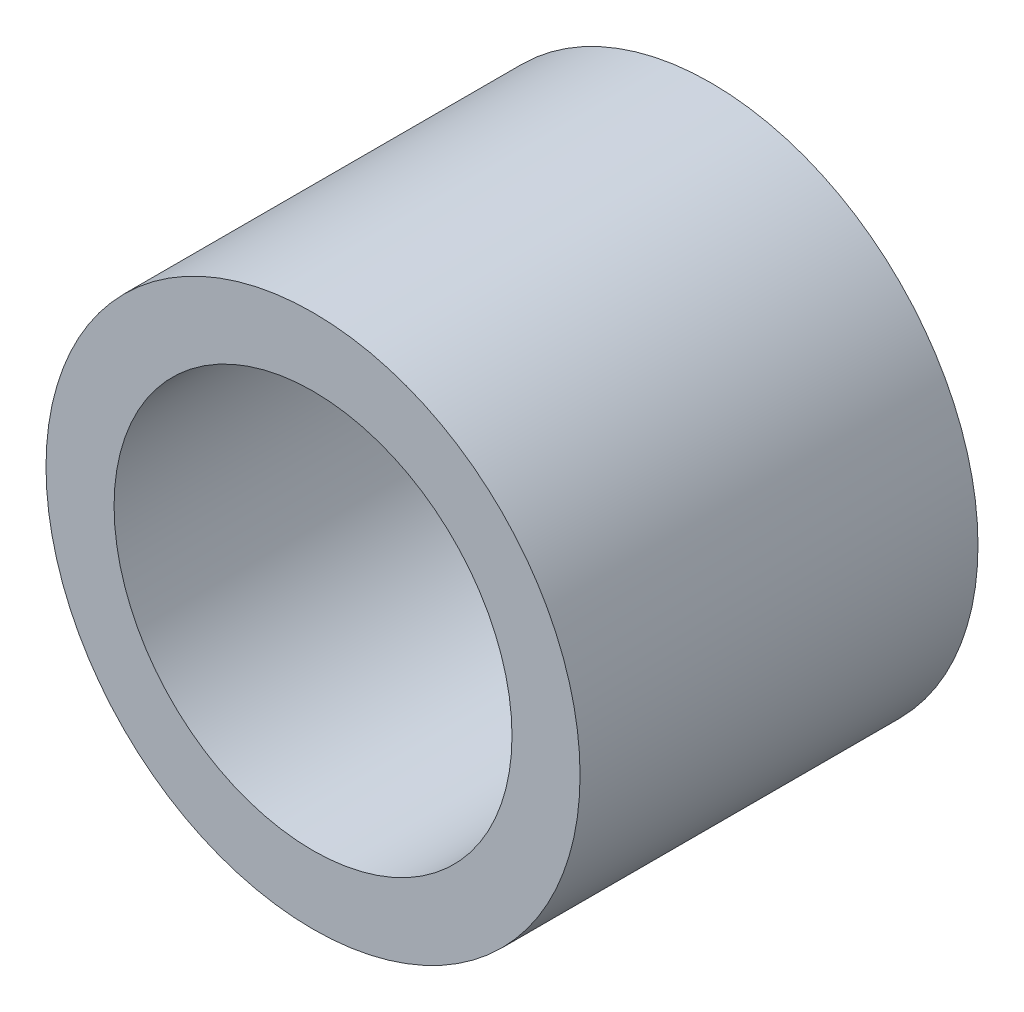
from build123d import *

# Parameters (mm, degrees)
SKETCH1_R           = 12.75
SKETCH1_R_2         = 9.5
BOSS_EXTRUDE1_DEPTH = 19


with BuildPart() as part:
    # Sketch1 → Boss-Extrude1 (new body)
    with BuildSketch(Plane.XY):
        Circle(SKETCH1_R)
        Circle(SKETCH1_R_2, mode=Mode.SUBTRACT)
    extrude(amount=BOSS_EXTRUDE1_DEPTH)


solid = part.part
